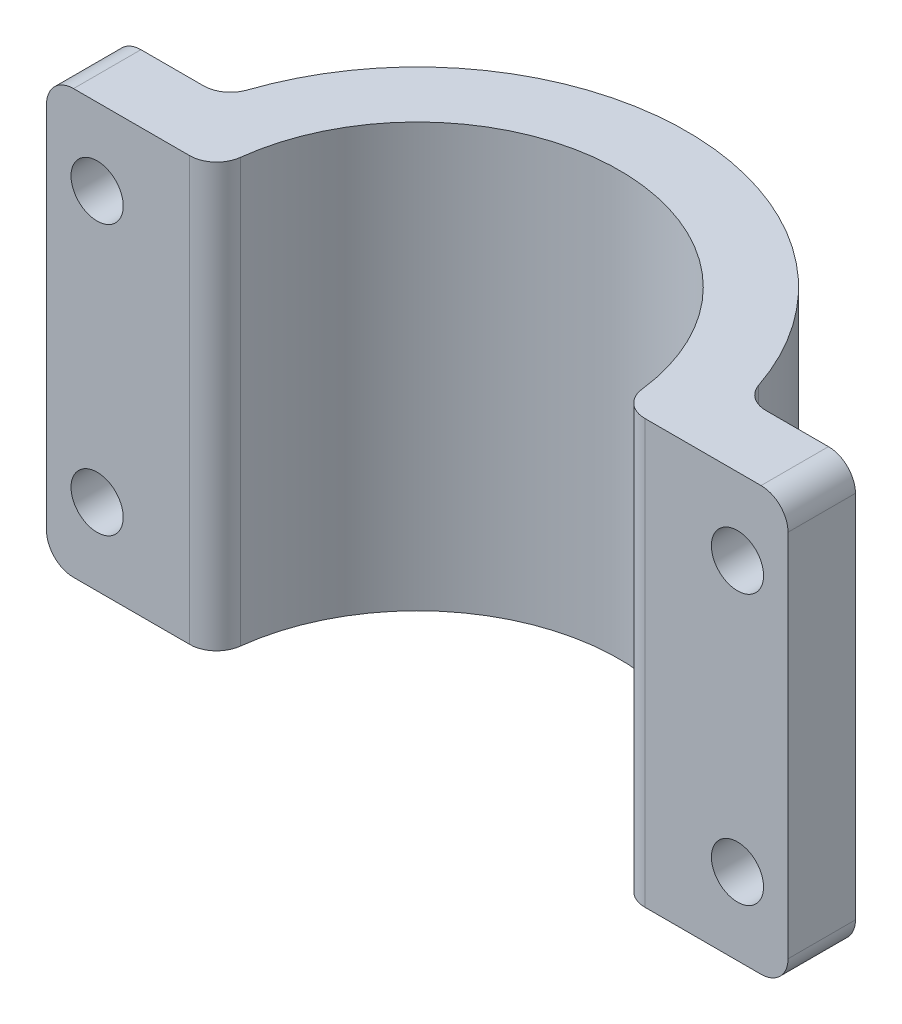
from build123d import *

# Parameters (mm, degrees)
BOSS_EXTRUDE2_DEPTH          = 39.878
FILLET1_R                    = 2.54
F_10_0_1935_DIAMETER_HOLE1_D = 4.9149


with BuildPart() as part:
    # Sketch5 → Boss-Extrude2 (new body)
    with BuildSketch(Plane(origin=(0, 0, 0), x_dir=(1, 0, 0), z_dir=(0, 1, 0))):
        with BuildLine():
            Line((-34.925, 0), (-19.05, 0))
            ThreePointArc((-19.05, 0), (0, 19.05), (19.05, 0))
            Line((19.05, 0), (34.925, 0))
            Line((34.925, 0), (34.925, 6.35))
            Line((34.925, 6.35), (24.593444248, 6.35))
            ThreePointArc((24.593444248, 6.35), (0, 25.4), (-24.593444248, 6.35))
            Line((-24.593444248, 6.35), (-34.925, 6.35))
            Line((-34.925, 6.35), (-34.925, 0))
        make_face()
    extrude(amount=-BOSS_EXTRUDE2_DEPTH)

    # Fillet1
    fillet1_edges = [part.edges().sort_by_distance(p)[0] for p in [
        (-34.925, 0, -3.175),
        (-24.593444248, -19.939, -6.35),
        (24.593444248, -19.939, -6.35),
        (19.05, -19.939, 0),
        (-19.05, -19.939, 0),
        (34.925, -39.878, -3.175),
        (-34.925, -39.878, -3.175),
        (34.925, 0, -3.175),
    ]]
    fillet(fillet1_edges, radius=FILLET1_R)

    # #10 (0.1935) Diameter Hole1 (through all)
    with Locations(Plane(origin=(0, 0, -6.35), x_dir=(-1, 0, 0), z_dir=(0, 0, -1))):
        with Locations((-30.1625, -7.239), (-30.1625, -32.639)):
            f_10_0_1935_diameter_hole1 = Hole(F_10_0_1935_DIAMETER_HOLE1_D / 2)

    # Mirror1: #10 (0.1935) Diameter Hole1 across plane
    add(f_10_0_1935_diameter_hole1.mirror(Plane(origin=(0, 0, 0), x_dir=(0, 0, 1), z_dir=(1, 0, 0))), mode=Mode.SUBTRACT)


solid = part.part
